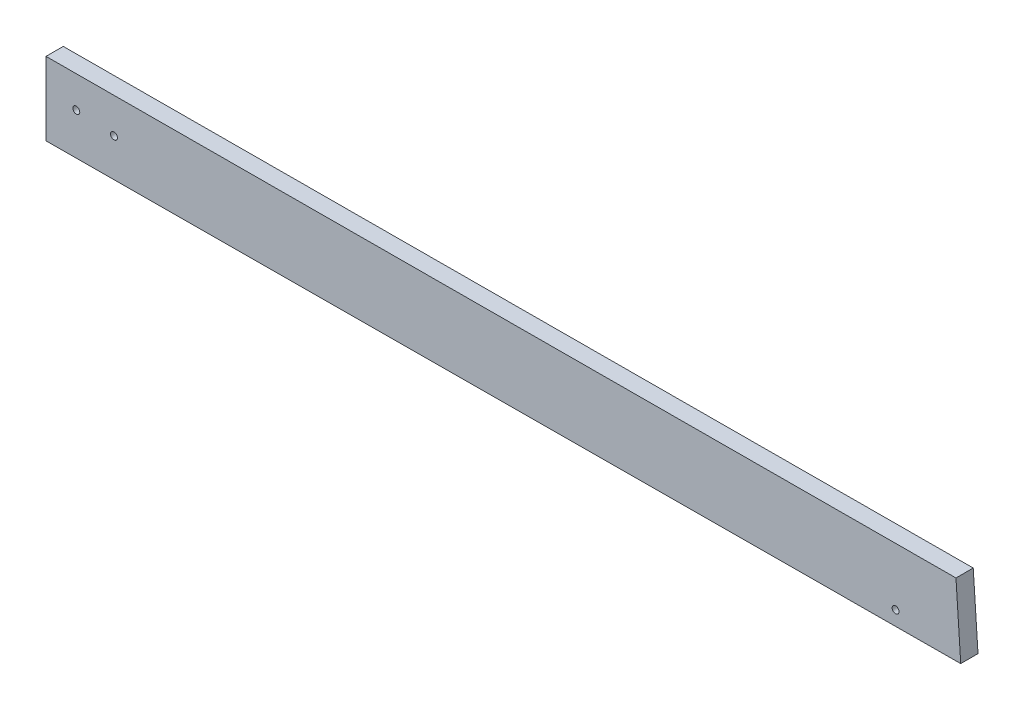
from build123d import *

# Parameters (mm, degrees)
SKETCH1_R           = 0.635
BOSS_EXTRUDE1_DEPTH = 3.175


with BuildPart() as part:
    # Sketch1 → Boss-Extrude1 (new body)
    with BuildSketch(Plane.XY):
        Polygon((169.876910838, 126.650867177), (1.5875, 125.794558197), (1.5875, 139.257710065), (169.000191682, 139.858675371), align=None)
        with Locations((157.892850269, 129.235572603)):
            Circle(SKETCH1_R, mode=Mode.SUBTRACT)
        with Locations((14.087503577, 132.842415442)):
            Circle(SKETCH1_R, mode=Mode.SUBTRACT)
        with Locations((7.163696951, 133.477415442)):
            Circle(SKETCH1_R, mode=Mode.SUBTRACT)
    extrude(amount=-BOSS_EXTRUDE1_DEPTH)


solid = part.part
